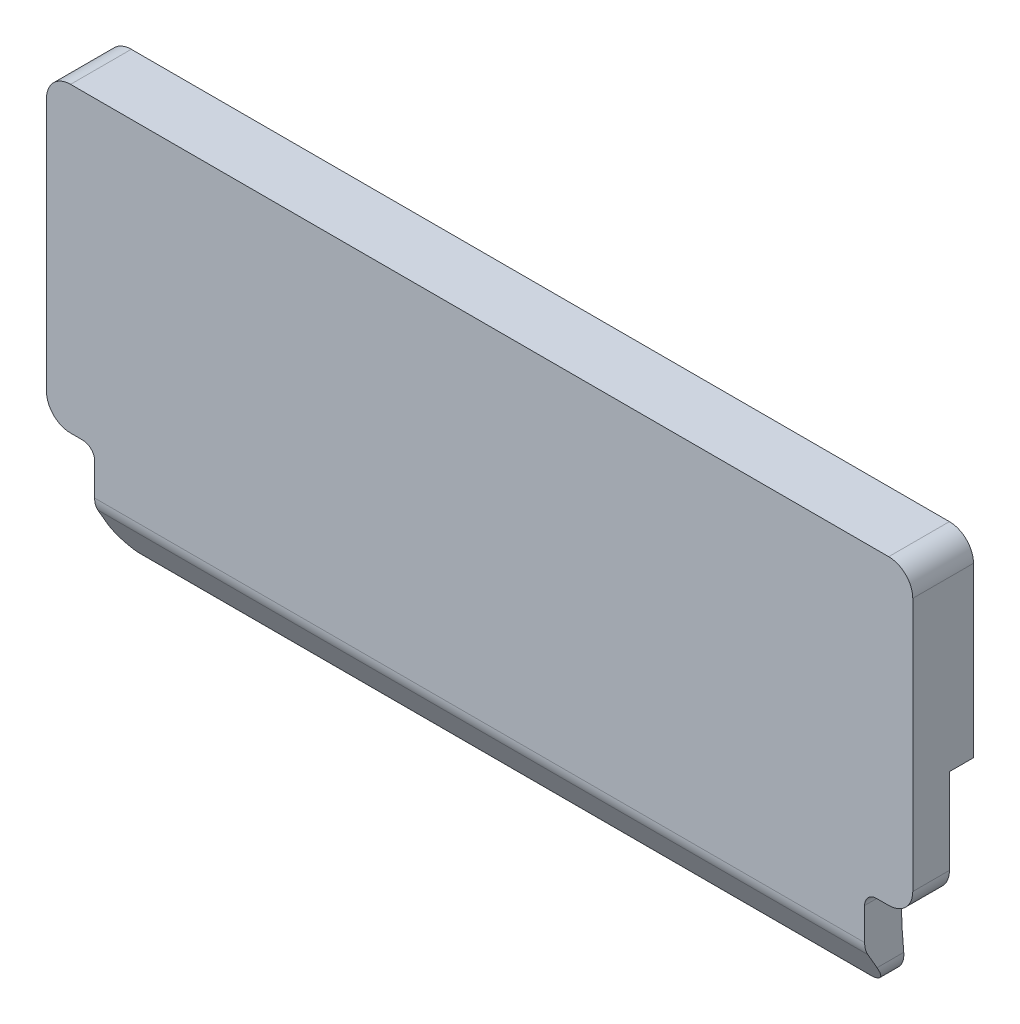
from build123d import *

# Parameters (mm, degrees)
BOSS_EXTRUDE1_DEPTH      = 1.5
BOSS_EXTRUDE1_DEPTH_BACK = 1.2
CUT_EXTRUDE1_DEPTH       = 40
FILLET1_R                = 1


with BuildPart() as part:
    # Sketch1 → Boss-Extrude1 (new body, two sides)
    with BuildSketch(Plane.XY) as boss_extrude1_sk:
        with BuildLine():
            Line((-17.999999991, 9.304537824), (-17.999999991, 10.304506021))
            Line((-17.999999991, 10.304506021), (-17.999999991, 17.303464443))
            ThreePointArc((-17.999999991, 17.303464443), (-17.707106772, 18.010571225), (-16.999999991, 18.303464443))
            Line((-16.999999991, 18.303464443), (16.999968161, 18.303464443))
            ThreePointArc((16.999968161, 18.303464443), (17.707074942, 18.010571225), (17.999968161, 17.303464443))
            Line((17.999968161, 17.303464443), (17.999968161, 9.303464443))
            Line((17.999968161, 9.303464443), (17.999968161, 6.751174458))
            ThreePointArc((17.999968161, 6.751174458), (17.707074942, 6.044067677), (16.999968161, 5.751174458))
            Line((16.999968161, 5.751174458), (16.499999991, 5.751174458))
            ThreePointArc((16.499999991, 5.751174458), (16.1464466, 5.604727849), (15.999999991, 5.251174458))
            Line((15.999999991, 5.251174458), (15.999999991, 2.751174458))
            ThreePointArc((15.999999991, 2.751174458), (15.707106772, 2.044067677), (14.999999991, 1.751174458))
            Line((14.999999991, 1.751174458), (-14.999999991, 1.751174458))
            ThreePointArc((-14.999999991, 1.751174458), (-15.707106772, 2.044067677), (-15.999999991, 2.751174458))
            Line((-15.999999991, 2.751174458), (-15.999999991, 5.251174458))
            ThreePointArc((-15.999999991, 5.251174458), (-16.1464466, 5.604727849), (-16.499999991, 5.751174458))
            Line((-16.499999991, 5.751174458), (-16.999999991, 5.751174458))
            ThreePointArc((-16.999999991, 5.751174458), (-17.707106772, 6.044067677), (-17.999999991, 6.751174458))
            Line((-17.999999991, 6.751174458), (-17.999999991, 9.304537824))
        make_face()
    extrude(amount=BOSS_EXTRUDE1_DEPTH)
    extrude(boss_extrude1_sk.sketch, amount=-BOSS_EXTRUDE1_DEPTH_BACK)

    # Sketch3 → Cut-Extrude1 (cut)
    with BuildSketch(Plane(origin=(17.999968161, 0, 0), x_dir=(0, 0, -1), z_dir=(1, 0, 0))):
        with BuildLine():
            Line((0.023796664, 5.754537824), (0.023796664, 10.304537824))
            Line((0.023796664, 10.304537824), (1.023796664, 10.304537824))
            Line((1.023796664, 10.304537824), (1.023796664, 22.680762846))
            ThreePointArc((1.023796664, 22.680762846), (7.212872074, 16.614024598), (1.2708887, 10.304537824))
            Line((1.2708887, 10.304537824), (1.2708887, 1.751174458))
            Line((1.2708887, 1.751174458), (0.23729316, 1.751174458))
            ThreePointArc((0.23729316, 1.751174458), (0.053060483, 3.748723952), (0.023796664, 5.754537824))
        make_face()
        with BuildLine():
            Line((-1.5, 3.645881873), (-1.5, 1.751174458))
            Line((-1.5, 1.751174458), (-0.306090164, 1.751174458))
            Line((-0.306090164, 1.751174458), (-0.348355137, 1.751174458))
            ThreePointArc((-0.348355137, 1.751174458), (-0.398355137, 1.764571918), (-0.434957677, 1.801174458))
            Line((-0.434957677, 1.801174458), (-1.5, 3.645881873))
        make_face()
    extrude(amount=-CUT_EXTRUDE1_DEPTH, mode=Mode.SUBTRACT)

    # Fillet1
    fillet1_edges = [part.edges().sort_by_distance(p)[0] for p in [
        (0, 3.645881873, 1.5),
    ]]
    fillet(fillet1_edges, radius=FILLET1_R)


solid = part.part
